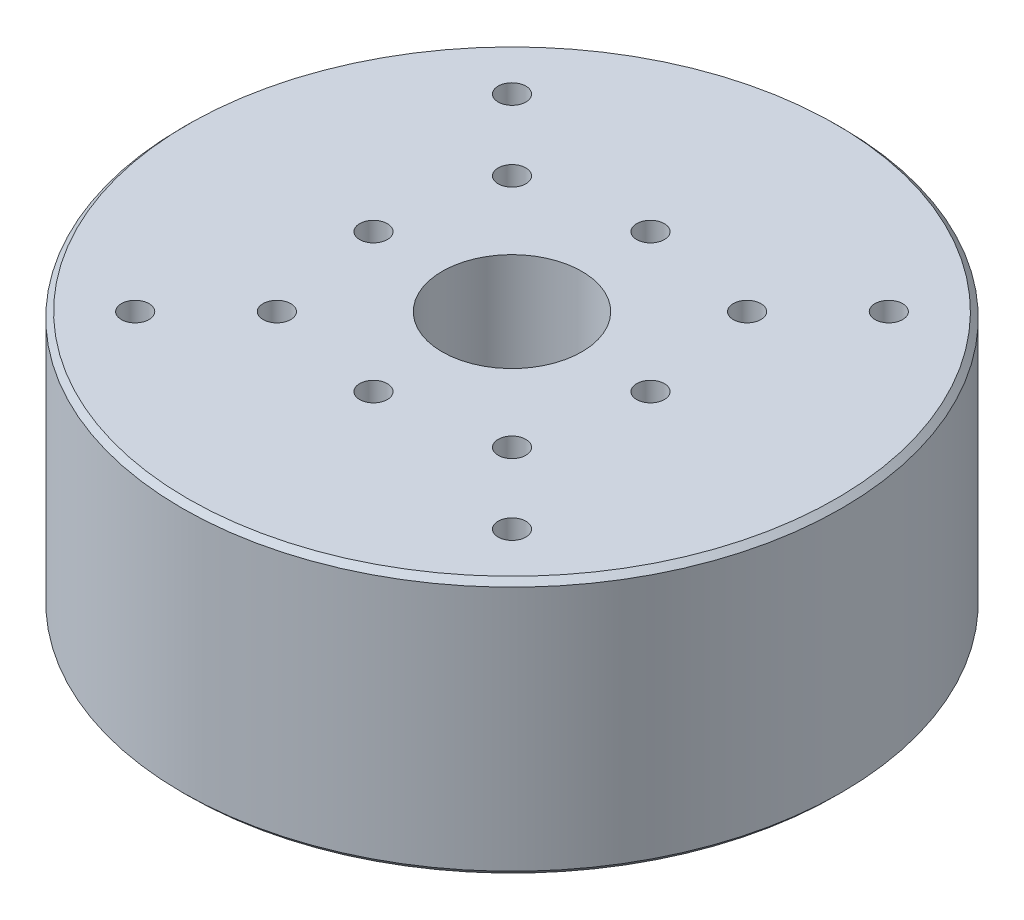
from build123d import *

# Parameters (mm, degrees)
SKETCH1_R                      = 29.75
BOSS_EXTRUDE1_DEPTH            = 23.2
SKETCH2_R                      = 6.3
CUT_EXTRUDE1_DEPTH             = 20.5
SKETCH3_R                      = 4.75
CUT_EXTRUDE2_DEPTH             = 2.7
CHAMFER1_SIZE                  = 0.5
CIRPATTERN1_COUNT              = 7
CIRPATTERN1_ANGLE              = 270
CIRPATTERN2_COUNT              = 4
CIRPATTERN3_COUNT              = 4
CUT_EXTRUDE3_DEPTH             = 5
FILLET1_R                      = 0.5
M3X0_5_TAPPED_HOLE4_D          = 2.5
M3X0_5_TAPPED_HOLE4_DEPTH      = 5
M3X0_5_TAPPED_HOLE4_TIP        = 0.751075774
M3X0_5_TAPPED_HOLE5_AT_2_COUNT = 2
M3X0_5_TAPPED_HOLE5_AT_2_PITCH = 10.774272925
CIRPATTERN4_COUNT              = 4


with BuildPart() as part:
    # Sketch1 → Boss-Extrude1 (new body)
    with BuildSketch(Plane(origin=(0, 0, 0), x_dir=(1, 0, 0), z_dir=(0, 1, 0))):
        Circle(SKETCH1_R)
    extrude(amount=BOSS_EXTRUDE1_DEPTH)

    # Sketch2 → Cut-Extrude1 (cut)
    with BuildSketch(Plane(origin=(0, 23.2, 0), x_dir=(1, 0, 0), z_dir=(0, 1, 0))):
        Circle(SKETCH2_R)
    extrude(amount=-CUT_EXTRUDE1_DEPTH, mode=Mode.SUBTRACT)

    # Sketch3 → Cut-Extrude2 (cut)
    with BuildSketch(Plane.XZ):
        Circle(SKETCH3_R)
    extrude(amount=-CUT_EXTRUDE2_DEPTH, mode=Mode.SUBTRACT)

    # Chamfer1
    chamfer1_edges = [part.edges().sort_by_distance(p)[0] for p in [
        (-29.75, 0, 0),
        (-29.75, 23.2, 0),
    ]]
    chamfer(chamfer1_edges, length=CHAMFER1_SIZE)

    # Sketch5 → M3x0.5 Tapped Hole1 (revolve, cut)
    with BuildSketch(Plane(origin=(0, 0, -22), x_dir=(0, 0, -1), z_dir=(1, 0, 0))):
        Polygon((0, 0), (0, 5.751075774), (1.25, 5), (1.25, 0), align=None)
    m3x0_5_tapped_hole1 = revolve(axis=Axis((0, -6.35, -22), (0, 1, 0)), mode=Mode.SUBTRACT)

    # CirPattern1: M3x0.5 Tapped Hole1 ×7 about axis
    cirpattern1_axis = Axis((0, 0, 0), (0, -1, 0))
    for i in range(1, CIRPATTERN1_COUNT):
        add(m3x0_5_tapped_hole1.rotate(cirpattern1_axis, i * CIRPATTERN1_ANGLE / (CIRPATTERN1_COUNT - 1)), mode=Mode.SUBTRACT)

    # Sketch7 → M3x0.5 Tapped Hole2 (revolve, cut)
    with BuildSketch(Plane(origin=(-8.838834765, 0, -8.838834765), x_dir=(0, 0, -1), z_dir=(1, 0, 0))):
        Polygon((0, 0), (0, 5.751075774), (1.25, 5), (1.25, 0), align=None)
    m3x0_5_tapped_hole2 = revolve(axis=Axis((-8.838834765, -6.35, -8.838834765), (0, 1, 0)), mode=Mode.SUBTRACT)

    # CirPattern2: M3x0.5 Tapped Hole2 ×4 about axis
    cirpattern2_axis = Axis((0, 0, 0), (0, 1, 0))
    for i in range(1, CIRPATTERN2_COUNT):
        add(m3x0_5_tapped_hole2.rotate(cirpattern2_axis, i * 360 / CIRPATTERN2_COUNT), mode=Mode.SUBTRACT)

    # Sketch9 → M3x0.5 Tapped Hole3 (revolve, cut)
    with BuildSketch(Plane(origin=(-15, 0, 0), x_dir=(0, 0, -1), z_dir=(1, 0, 0))):
        Polygon((0, 0), (0, 5.751075774), (1.25, 5), (1.25, 0), align=None)
    m3x0_5_tapped_hole3 = revolve(axis=Axis((-15, -6.35, 0), (0, 1, 0)), mode=Mode.SUBTRACT)

    # CirPattern3: M3x0.5 Tapped Hole3 ×4 about axis
    cirpattern3_axis = Axis((0, 0, 0), (0, 1, 0))
    for i in range(1, CIRPATTERN3_COUNT):
        add(m3x0_5_tapped_hole3.rotate(cirpattern3_axis, i * 360 / CIRPATTERN3_COUNT), mode=Mode.SUBTRACT)

    # Sketch10 → Cut-Extrude3 (cut)
    with BuildSketch(Plane.XZ):
        Polygon((-20.11656159, -13.815821112), (-13.045493778, -20.886888923), (-15.873920903, -23.715316048), (-22.944988715, -16.644248236), align=None)
    extrude(amount=-CUT_EXTRUDE3_DEPTH, mode=Mode.SUBTRACT)

    # Fillet1
    fillet1_edges = [part.edges().sort_by_distance(p)[0] for p in [
        (-22.944988715, 2.5, -16.644248236),
        (-20.11656159, 2.5, -13.815821112),
        (-13.045493778, 2.5, -20.886888923),
        (-15.873920903, 2.5, -23.715316048),
    ]]
    fillet(fillet1_edges, radius=FILLET1_R)

    # M3x0.5 Tapped Hole4
    with Locations(Plane(origin=(0, 23.2, 0), x_dir=(1, 0, 0), z_dir=(0, 1, 0))):
        with Locations((-17, 17), (-17, -17), (17, -17), (17, 17)):
            Hole(M3X0_5_TAPPED_HOLE4_D / 2, depth=M3X0_5_TAPPED_HOLE4_DEPTH)
            with Locations((0, 0, -(M3X0_5_TAPPED_HOLE4_DEPTH + M3X0_5_TAPPED_HOLE4_TIP / 2))):  # 118° drill point
                Cone(0, M3X0_5_TAPPED_HOLE4_D / 2, M3X0_5_TAPPED_HOLE4_TIP, mode=Mode.SUBTRACT)

    # Sketch14 → M3x0.5 Tapped Hole5 (revolve, cut)
    with BuildSketch(Plane(origin=(12.5, 23.2, 0), x_dir=(0, 0, 1), z_dir=(1, 0, 0))):
        Polygon((0, 0), (0, 5.751075774), (1.25, 5), (1.25, 0), align=None)
    m3x0_5_tapped_hole5 = revolve(axis=Axis((12.5, 29.55, 0), (0, -1, 0)), mode=Mode.SUBTRACT)

    # M3x0.5 Tapped Hole5 at 2: M3x0.5 Tapped Hole5 ×2
    with Locations(*[Vector(-0.175733276, 0, -0.984437817) * (i * M3X0_5_TAPPED_HOLE5_AT_2_PITCH) for i in range(1, M3X0_5_TAPPED_HOLE5_AT_2_COUNT)]):
        add(m3x0_5_tapped_hole5, mode=Mode.SUBTRACT)

    # CirPattern4: M3x0.5 Tapped Hole5 ×4 about axis
    cirpattern4_axis = Axis((0, 0, 0), (0, 1, 0))
    for i in range(1, CIRPATTERN4_COUNT):
        add(m3x0_5_tapped_hole5.rotate(cirpattern4_axis, i * 360 / CIRPATTERN4_COUNT), mode=Mode.SUBTRACT)

    # CirPattern4 copy 1 sketch → CirPattern4 copy 1 (revolve, cut)
    with BuildSketch(Plane(origin=(-10.606601718, 23.2, -10.606601718), x_dir=(1, 0, 0), z_dir=(0, 0, -1))):
        Polygon((0, 0), (0, 5.751075774), (1.25, 5), (1.25, 0), align=None)
    revolve(axis=Axis((-10.606601718, 29.55, -10.606601718), (0, -1, 0)), mode=Mode.SUBTRACT)

    # CirPattern4 copy 2 sketch → CirPattern4 copy 2 (revolve, cut)
    with BuildSketch(Plane(origin=(-10.606601718, 23.2, 10.606601718), x_dir=(0, 0, -1), z_dir=(-1, 0, 0))):
        Polygon((0, 0), (0, 5.751075774), (1.25, 5), (1.25, 0), align=None)
    revolve(axis=Axis((-10.606601718, 29.55, 10.606601718), (0, -1, 0)), mode=Mode.SUBTRACT)

    # CirPattern4 copy 3 sketch → CirPattern4 copy 3 (revolve, cut)
    with BuildSketch(Plane(origin=(10.606601718, 23.2, 10.606601718), x_dir=(-1, 0, 0), z_dir=(0, 0, 1))):
        Polygon((0, 0), (0, 5.751075774), (1.25, 5), (1.25, 0), align=None)
    revolve(axis=Axis((10.606601718, 29.55, 10.606601718), (0, -1, 0)), mode=Mode.SUBTRACT)


solid = part.part
